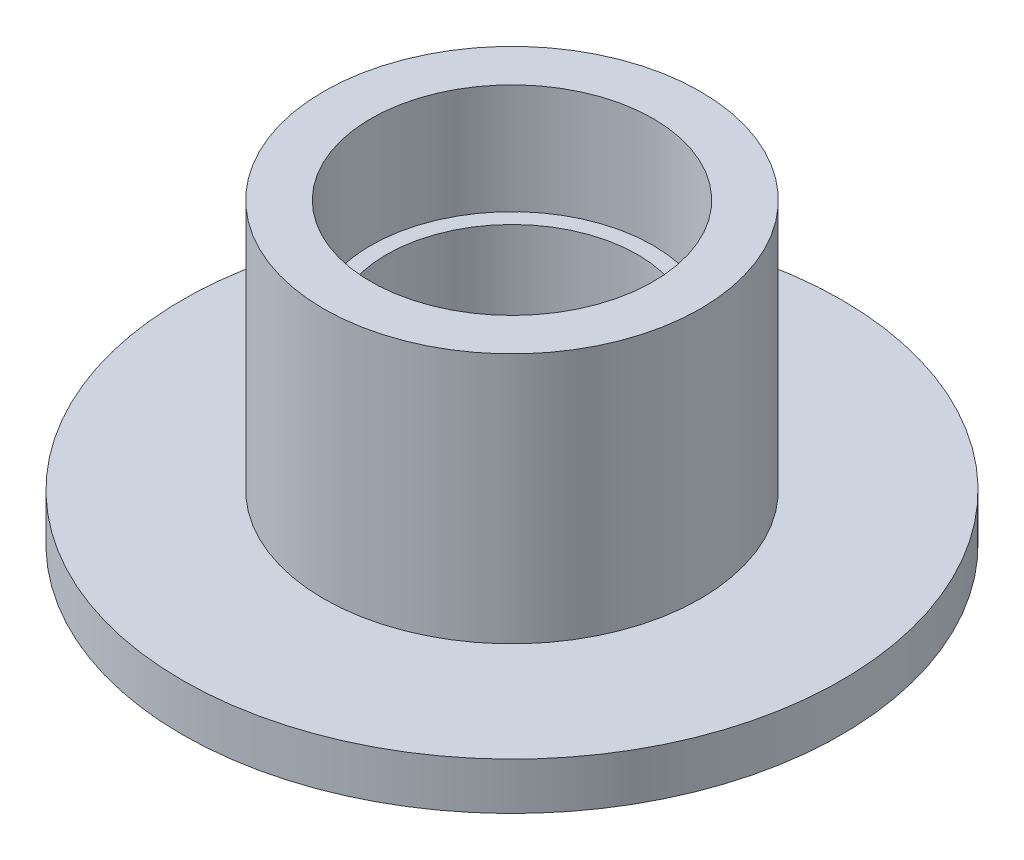
from build123d import *


with BuildPart() as part:
    # Esquisse1 → Révolution1 (revolve)
    with BuildSketch(Plane.XY, mode=Mode.PRIVATE) as r_volution1_sk:
        Polygon((-2, 3.845299462), (-2, 0), (-3, 0), (-3, 3), (-10.5, 3), (-10.5, 4.5), (-6, 4.5), (-6, 12.5), (-4.5, 12.5), (-4.5, 9), (-4, 9), (-4, 5), align=None)
    revolve(r_volution1_sk.sketch.rotate(Axis((0, 0, 0), (0, 1, 0)), 270), axis=Axis((0, 0, 0), (0, 1, 0)))  # turned: the seam where the file's is


solid = part.part
